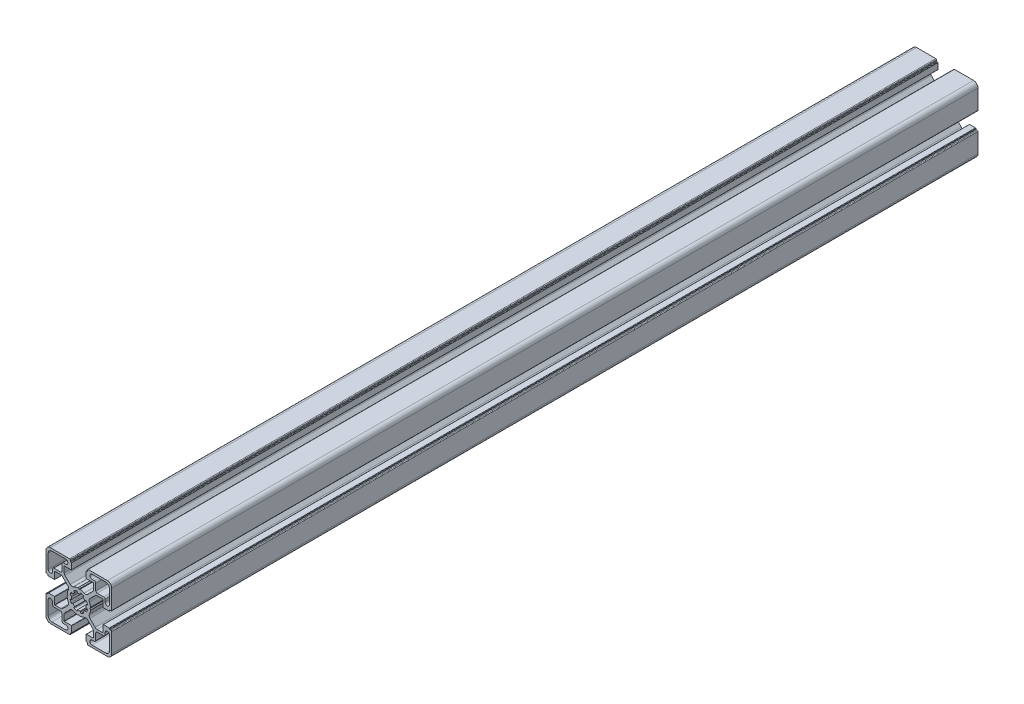
from build123d import *

# Parameters (mm, degrees)
BASE_EXTRUDE_DEPTH = 593


with BuildPart() as part:
    # Sketch1 → Base-Extrude (new body)
    with BuildSketch(Plane.XY):
        with BuildLine():
            Line((7.973976585, 0.792591518), (7.540060475, 0.046829556))
            ThreePointArc((7.540060475, 0.046829556), (7.534295984, 0.023675638), (7.531329941, 0))
            ThreePointArc((7.531329941, 0), (7.534295984, -0.023675638), (7.540060475, -0.046829556))
            Line((7.540060475, -0.046829556), (7.973976585, -0.792591518))
            ThreePointArc((7.973976585, -0.792591518), (7.996666421, -0.851255641), (8.000014047, -0.914065683))
            ThreePointArc((8.000014047, -0.914065683), (7.719730741, -2.298395946), (7.20036345, -3.611859543))
            ThreePointArc((7.20036345, -3.611859543), (7.018857217, -4.793954471), (7.563483933, -5.85869607))
            Line((7.563483933, -5.85869607), (11.129779889, -9.424988026))
            ThreePointArc((11.129779889, -9.424988026), (11.760624613, -9.84650461), (12.504756513, -9.99452154))
            Line((12.504756513, -9.99452154), (16.316902451, -9.99452154))
            ThreePointArc((16.316902451, -9.99452154), (16.458324055, -9.935942793), (16.516902802, -9.794521189))
            Line((16.516902802, -9.794521189), (16.516902802, -5.200014226))
            ThreePointArc((16.516902802, -5.200014226), (16.575481548, -5.058592621), (16.716903152, -5.000013875))
            Line((16.716903152, -5.000013875), (20.719599904, -5.000013875))
            ThreePointArc((20.719599904, -5.000013875), (20.931731427, -5.087881629), (21.01959918, -5.300013151))
            Line((21.01959918, -5.300013151), (21.01959918, -5.500004099))
            ThreePointArc((21.01959918, -5.500004099), (21.10746708, -5.712135974), (21.319598956, -5.800003874))
            Line((21.319598956, -5.800003874), (21.999979514, -5.800003874))
            ThreePointArc((21.999979514, -5.800003874), (22.35353264, -5.946450374), (22.49997914, -6.300003501))
            Line((22.49997914, -6.300003501), (22.49997914, -19.500016116))
            ThreePointArc((22.49997914, -19.500016116), (21.62130014, -21.621334875), (19.499981381, -22.500013875))
            Line((19.499981381, -22.500013875), (6.375709012, -22.500013875))
            ThreePointArc((6.375709012, -22.500013875), (6.022155886, -22.353567375), (5.875709386, -22.000014249))
            Line((5.875709386, -22.000014249), (5.875709386, -21.30001315))
            ThreePointArc((5.875709386, -21.30001315), (5.787841632, -21.087881628), (5.57571011, -21.000013874))
            Line((5.57571011, -21.000013874), (5.299998776, -21.000013874))
            ThreePointArc((5.299998776, -21.000013874), (5.087867607, -20.912146267), (5, -20.700015099))
            Line((5, -20.700015099), (5, -16.666812433))
            ThreePointArc((5, -16.666812433), (5.058578893, -16.525390475), (5.200000851, -16.466811582))
            Line((5.200000851, -16.466811582), (9.905385218, -16.466811582))
            ThreePointArc((9.905385218, -16.466811582), (10.046806822, -16.408232835), (10.105385569, -16.266811231))
            Line((10.105385569, -16.266811231), (10.105385569, -12.471582956))
            ThreePointArc((10.105385569, -12.471582956), (9.953144588, -11.706215861), (9.519598955, -11.057368968))
            Line((9.519598955, -11.057368968), (5.944897989, -7.482668002))
            ThreePointArc((5.944897989, -7.482668002), (4.854601835, -6.967833724), (3.666499237, -7.173289937))
            ThreePointArc((3.666499237, -7.173289937), (2.309136684, -7.713848333), (0.876396038, -8.000013875))
            ThreePointArc((0.876396038, -8.000013875), (0.81356491, -7.997088573), (0.754749577, -7.974793627))
            Line((0.754749577, -7.974793627), (0.11262846, -7.606936933))
            ThreePointArc((0.11262846, -7.606936933), (0.062963903, -7.559088739), (0, -7.530953975))
            ThreePointArc((0, -7.530953975), (-0.062963903, -7.559088739), (-0.11262846, -7.606936933))
            Line((-0.11262846, -7.606936933), (-0.754749577, -7.974793627))
            ThreePointArc((-0.754749577, -7.974793627), (-0.81356491, -7.997088573), (-0.876396038, -8.000013875))
            ThreePointArc((-0.876396038, -8.000013875), (-2.309136684, -7.713848333), (-3.666499237, -7.173289937))
            ThreePointArc((-3.666499237, -7.173289937), (-4.854601835, -6.967833724), (-5.944897989, -7.482668002))
            Line((-5.944897989, -7.482668002), (-9.519598955, -11.057368968))
            ThreePointArc((-9.519598955, -11.057368968), (-9.953144588, -11.706215861), (-10.105385569, -12.471582956))
            Line((-10.105385569, -12.471582956), (-10.105385569, -16.266811231))
            ThreePointArc((-10.105385569, -16.266811231), (-10.046806822, -16.408232835), (-9.905385218, -16.466811582))
            Line((-9.905385218, -16.466811582), (-5.200000851, -16.466811582))
            ThreePointArc((-5.200000851, -16.466811582), (-5.058578893, -16.525390475), (-5, -16.666812433))
            Line((-5, -16.666812433), (-5, -20.700015099))
            ThreePointArc((-5, -20.700015099), (-5.087867607, -20.912146267), (-5.299998776, -21.000013874))
            Line((-5.299998776, -21.000013874), (-5.57571011, -21.000013874))
            ThreePointArc((-5.57571011, -21.000013874), (-5.787841632, -21.087881628), (-5.875709386, -21.30001315))
            Line((-5.875709386, -21.30001315), (-5.875709386, -22.000014249))
            ThreePointArc((-5.875709386, -22.000014249), (-6.022155886, -22.353567375), (-6.375709012, -22.500013875))
            Line((-6.375709012, -22.500013875), (-19.499981381, -22.500013875))
            ThreePointArc((-19.499981381, -22.500013875), (-21.62130014, -21.621334875), (-22.49997914, -19.500016116))
            Line((-22.49997914, -19.500016116), (-22.49997914, -6.300003501))
            ThreePointArc((-22.49997914, -6.300003501), (-22.35353264, -5.946450374), (-21.999979514, -5.800003874))
            Line((-21.999979514, -5.800003874), (-21.319598956, -5.800003874))
            ThreePointArc((-21.319598956, -5.800003874), (-21.10746708, -5.712135974), (-21.01959918, -5.500004099))
            Line((-21.01959918, -5.500004099), (-21.01959918, -5.300013151))
            ThreePointArc((-21.01959918, -5.300013151), (-20.931731427, -5.087881629), (-20.719599904, -5.000013875))
            Line((-20.719599904, -5.000013875), (-16.716903152, -5.000013875))
            ThreePointArc((-16.716903152, -5.000013875), (-16.575481548, -5.058592621), (-16.516902802, -5.200014226))
            Line((-16.516902802, -5.200014226), (-16.516902802, -9.794521189))
            ThreePointArc((-16.516902802, -9.794521189), (-16.458324055, -9.935942793), (-16.316902451, -9.99452154))
            Line((-16.316902451, -9.99452154), (-12.504756513, -9.99452154))
            ThreePointArc((-12.504756513, -9.99452154), (-11.760624613, -9.84650461), (-11.129779889, -9.424988026))
            Line((-11.129779889, -9.424988026), (-7.563483933, -5.85869607))
            ThreePointArc((-7.563483933, -5.85869607), (-7.018857217, -4.793954471), (-7.20036345, -3.611859543))
            ThreePointArc((-7.20036345, -3.611859543), (-7.719730741, -2.298395946), (-8.000014047, -0.914065683))
            ThreePointArc((-8.000014047, -0.914065683), (-7.996666421, -0.851255641), (-7.973976585, -0.792591518))
            Line((-7.973976585, -0.792591518), (-7.540060475, -0.046829556))
            ThreePointArc((-7.540060475, -0.046829556), (-7.534295984, -0.023675638), (-7.531329941, 0))
            ThreePointArc((-7.531329941, 0), (-7.534295984, 0.023675638), (-7.540060475, 0.046829556))
            Line((-7.540060475, 0.046829556), (-7.973976585, 0.792591518))
            ThreePointArc((-7.973976585, 0.792591518), (-7.996666421, 0.851255641), (-8.000014047, 0.914065683))
            ThreePointArc((-8.000014047, 0.914065683), (-7.719730741, 2.298395946), (-7.20036345, 3.611859543))
            ThreePointArc((-7.20036345, 3.611859543), (-7.018857217, 4.793954471), (-7.563483933, 5.85869607))
            Line((-7.563483933, 5.85869607), (-11.129779889, 9.424988026))
            ThreePointArc((-11.129779889, 9.424988026), (-11.760624613, 9.84650461), (-12.504756513, 9.99452154))
            Line((-12.504756513, 9.99452154), (-16.316902451, 9.99452154))
            ThreePointArc((-16.316902451, 9.99452154), (-16.458324055, 9.935942793), (-16.516902802, 9.794521189))
            Line((-16.516902802, 9.794521189), (-16.516902802, 5.200014226))
            ThreePointArc((-16.516902802, 5.200014226), (-16.575481548, 5.058592621), (-16.716903152, 5.000013875))
            Line((-16.716903152, 5.000013875), (-20.719599904, 5.000013875))
            ThreePointArc((-20.719599904, 5.000013875), (-20.931731427, 5.087881629), (-21.01959918, 5.300013151))
            Line((-21.01959918, 5.300013151), (-21.01959918, 5.500004099))
            ThreePointArc((-21.01959918, 5.500004099), (-21.10746708, 5.712135974), (-21.319598956, 5.800003874))
            Line((-21.319598956, 5.800003874), (-21.999979514, 5.800003874))
            ThreePointArc((-21.999979514, 5.800003874), (-22.35353264, 5.946450374), (-22.49997914, 6.300003501))
            Line((-22.49997914, 6.300003501), (-22.49997914, 19.500016116))
            ThreePointArc((-22.49997914, 19.500016116), (-21.62130014, 21.621334875), (-19.499981381, 22.500013875))
            Line((-19.499981381, 22.500013875), (-6.375709012, 22.500013875))
            ThreePointArc((-6.375709012, 22.500013875), (-6.022155886, 22.353567375), (-5.875709386, 22.000014249))
            Line((-5.875709386, 22.000014249), (-5.875709386, 21.30001315))
            ThreePointArc((-5.875709386, 21.30001315), (-5.787841632, 21.087881628), (-5.57571011, 21.000013874))
            Line((-5.57571011, 21.000013874), (-5.299998776, 21.000013874))
            ThreePointArc((-5.299998776, 21.000013874), (-5.087867607, 20.912146267), (-5, 20.700015099))
            Line((-5, 20.700015099), (-5, 16.666812433))
            ThreePointArc((-5, 16.666812433), (-5.058578893, 16.525390475), (-5.200000851, 16.466811582))
            Line((-5.200000851, 16.466811582), (-9.905385218, 16.466811582))
            ThreePointArc((-9.905385218, 16.466811582), (-10.046806822, 16.408232835), (-10.105385569, 16.266811231))
            Line((-10.105385569, 16.266811231), (-10.105385569, 12.471582956))
            ThreePointArc((-10.105385569, 12.471582956), (-9.953144588, 11.706215861), (-9.519598955, 11.057368968))
            Line((-9.519598955, 11.057368968), (-5.944897989, 7.482668002))
            ThreePointArc((-5.944897989, 7.482668002), (-4.854601835, 6.967833724), (-3.666499237, 7.173289937))
            ThreePointArc((-3.666499237, 7.173289937), (-2.309136684, 7.713848333), (-0.876396038, 8.000013875))
            ThreePointArc((-0.876396038, 8.000013875), (-0.81356491, 7.997088573), (-0.754749577, 7.974793627))
            Line((-0.754749577, 7.974793627), (-0.11262846, 7.606936933))
            ThreePointArc((-0.11262846, 7.606936933), (-0.062963903, 7.559088739), (0, 7.530953975))
            ThreePointArc((0, 7.530953975), (0.062963903, 7.559088739), (0.11262846, 7.606936933))
            Line((0.11262846, 7.606936933), (0.754749577, 7.974793627))
            ThreePointArc((0.754749577, 7.974793627), (0.81356491, 7.997088573), (0.876396038, 8.000013875))
            ThreePointArc((0.876396038, 8.000013875), (2.309136684, 7.713848333), (3.666499237, 7.173289937))
            ThreePointArc((3.666499237, 7.173289937), (4.854601835, 6.967833724), (5.944897989, 7.482668002))
            Line((5.944897989, 7.482668002), (9.519598955, 11.057368968))
            ThreePointArc((9.519598955, 11.057368968), (9.953144588, 11.706215861), (10.105385569, 12.471582956))
            Line((10.105385569, 12.471582956), (10.105385569, 16.266811231))
            ThreePointArc((10.105385569, 16.266811231), (10.046806822, 16.408232835), (9.905385218, 16.466811582))
            Line((9.905385218, 16.466811582), (5.200000851, 16.466811582))
            ThreePointArc((5.200000851, 16.466811582), (5.058578893, 16.525390475), (5, 16.666812433))
            Line((5, 16.666812433), (5, 20.700015099))
            ThreePointArc((5, 20.700015099), (5.087867607, 20.912146267), (5.299998776, 21.000013874))
            Line((5.299998776, 21.000013874), (5.57571011, 21.000013874))
            ThreePointArc((5.57571011, 21.000013874), (5.787841632, 21.087881628), (5.875709386, 21.30001315))
            Line((5.875709386, 21.30001315), (5.875709386, 22.000014249))
            ThreePointArc((5.875709386, 22.000014249), (6.022155886, 22.353567375), (6.375709012, 22.500013875))
            Line((6.375709012, 22.500013875), (19.499981381, 22.500013875))
            ThreePointArc((19.499981381, 22.500013875), (21.62130014, 21.621334875), (22.49997914, 19.500016116))
            Line((22.49997914, 19.500016116), (22.49997914, 6.300003501))
            ThreePointArc((22.49997914, 6.300003501), (22.35353264, 5.946450374), (21.999979514, 5.800003874))
            Line((21.999979514, 5.800003874), (21.319598956, 5.800003874))
            ThreePointArc((21.319598956, 5.800003874), (21.10746708, 5.712135974), (21.01959918, 5.500004099))
            Line((21.01959918, 5.500004099), (21.01959918, 5.300013151))
            ThreePointArc((21.01959918, 5.300013151), (20.931731427, 5.087881629), (20.719599904, 5.000013875))
            Line((20.719599904, 5.000013875), (16.716903152, 5.000013875))
            ThreePointArc((16.716903152, 5.000013875), (16.575481548, 5.058592621), (16.516902802, 5.200014226))
            Line((16.516902802, 5.200014226), (16.516902802, 9.794521189))
            ThreePointArc((16.516902802, 9.794521189), (16.458324055, 9.935942793), (16.316902451, 9.99452154))
            Line((16.316902451, 9.99452154), (12.504756513, 9.99452154))
            ThreePointArc((12.504756513, 9.99452154), (11.760624613, 9.84650461), (11.129779889, 9.424988026))
            Line((11.129779889, 9.424988026), (7.563483933, 5.85869607))
            ThreePointArc((7.563483933, 5.85869607), (7.018857217, 4.793954471), (7.20036345, 3.611859543))
            ThreePointArc((7.20036345, 3.611859543), (7.719730741, 2.298395946), (8.000014047, 0.914065683))
            ThreePointArc((8.000014047, 0.914065683), (7.996666421, 0.851255641), (7.973976585, 0.792591518))
        make_face()
        with BuildLine():
            Line((10.549978885, 18.000013874), (8.999979138, 18.000013874))
            ThreePointArc((8.999979138, 18.000013874), (7.499979138, 19.500013874), (8.999979138, 21.000013874))
            Line((8.999979138, 21.000013874), (18.499981006, 21.000013874))
            ThreePointArc((18.499981006, 21.000013874), (20.267746638, 20.267781374), (20.999979138, 18.500015742))
            Line((20.999979138, 18.500015742), (20.999979138, 9.000204874))
            ThreePointArc((20.999979138, 9.000204874), (19.499979138, 7.500204874), (17.999979138, 9.000204874))
            Line((17.999979138, 9.000204874), (17.999979138, 10.550013621))
            ThreePointArc((17.999979138, 10.550013621), (17.707086138, 11.257119874), (16.999979885, 11.550012874))
            Line((16.999979885, 11.550012874), (12.549977391, 11.550012874))
            ThreePointArc((12.549977391, 11.550012874), (11.842871138, 11.842905874), (11.549978138, 12.550012127))
            Line((11.549978138, 12.550012127), (11.549978138, 17.000014621))
            ThreePointArc((11.549978138, 17.000014621), (11.257085138, 17.707120874), (10.549978885, 18.000013874))
        make_face(mode=Mode.SUBTRACT)
        with BuildLine():
            Line((-0.867388737, 4.924188946), (-0.96752168, 5.481112935))
            ThreePointArc((-0.96752168, 5.481112935), (-1.187855719, 5.829589164), (-1.595071417, 5.894072848))
            ThreePointArc((-1.595071417, 5.894072848), (-2.338895973, 5.643477696), (-3.04438497, 5.299445466))
            ThreePointArc((-3.04438497, 5.299445466), (-3.284615367, 4.964275075), (-3.191311906, 4.562598216))
            Line((-3.191311906, 4.562598216), (-2.864000421, 4.09847552))
            ThreePointArc((-2.864000421, 4.09847552), (-3.53013295, 3.540926624), (-4.08971289, 2.876499344))
            Line((-4.08971289, 2.876499344), (-4.566777651, 3.208162503))
            ThreePointArc((-4.566777651, 3.208162503), (-4.968960845, 3.298770682), (-5.302497889, 3.056460542))
            ThreePointArc((-5.302497889, 3.056460542), (-5.651259984, 2.353310881), (-5.906847665, 1.611199444))
            ThreePointArc((-5.906847665, 1.611199444), (-5.839752063, 1.204293023), (-5.489730697, 0.98621116))
            Line((-5.489730697, 0.98621116), (-4.920545766, 0.887822825))
            ThreePointArc((-4.920545766, 0.887822825), (-4.980096828, 0.445685524), (-5, 0))
            ThreePointArc((-5, 0), (-4.980096828, -0.445685524), (-4.920545766, -0.887822825))
            Line((-4.920545766, -0.887822825), (-5.489730697, -0.98621116))
            ThreePointArc((-5.489730697, -0.98621116), (-5.839752063, -1.204293023), (-5.906847665, -1.611199444))
            ThreePointArc((-5.906847665, -1.611199444), (-5.651259984, -2.353310881), (-5.302497889, -3.056460542))
            ThreePointArc((-5.302497889, -3.056460542), (-4.968960845, -3.298770682), (-4.566777651, -3.208162503))
            Line((-4.566777651, -3.208162503), (-4.08971289, -2.876499344))
            ThreePointArc((-4.08971289, -2.876499344), (-3.53013295, -3.540926624), (-2.864000421, -4.09847552))
            Line((-2.864000421, -4.09847552), (-3.191311906, -4.562598216))
            ThreePointArc((-3.191311906, -4.562598216), (-3.284615367, -4.964275075), (-3.04438497, -5.299445466))
            ThreePointArc((-3.04438497, -5.299445466), (-2.338895973, -5.643477696), (-1.595071417, -5.894072848))
            ThreePointArc((-1.595071417, -5.894072848), (-1.187855719, -5.829589164), (-0.96752168, -5.481112935))
            Line((-0.96752168, -5.481112935), (-0.867388737, -4.924188946))
            ThreePointArc((-0.867388737, -4.924188946), (0, -5), (0.867388737, -4.924188946))
            Line((0.867388737, -4.924188946), (0.96752168, -5.481112935))
            ThreePointArc((0.96752168, -5.481112935), (1.187855719, -5.829589164), (1.595071417, -5.894072848))
            ThreePointArc((1.595071417, -5.894072848), (2.338895973, -5.643477696), (3.04438497, -5.299445466))
            ThreePointArc((3.04438497, -5.299445466), (3.284615367, -4.964275075), (3.191311906, -4.562598216))
            Line((3.191311906, -4.562598216), (2.864000421, -4.09847552))
            ThreePointArc((2.864000421, -4.09847552), (3.53013295, -3.540926624), (4.08971289, -2.876499344))
            Line((4.08971289, -2.876499344), (4.566777651, -3.208162503))
            ThreePointArc((4.566777651, -3.208162503), (4.968960845, -3.298770682), (5.302497889, -3.056460542))
            ThreePointArc((5.302497889, -3.056460542), (5.651259984, -2.353310881), (5.906847665, -1.611199444))
            ThreePointArc((5.906847665, -1.611199444), (5.839752063, -1.204293023), (5.489730697, -0.98621116))
            Line((5.489730697, -0.98621116), (4.920545766, -0.887822825))
            ThreePointArc((4.920545766, -0.887822825), (4.980096828, -0.445685524), (5, 0))
            ThreePointArc((5, 0), (4.980096828, 0.445685524), (4.920545766, 0.887822825))
            Line((4.920545766, 0.887822825), (5.489730697, 0.98621116))
            ThreePointArc((5.489730697, 0.98621116), (5.839752063, 1.204293023), (5.906847665, 1.611199444))
            ThreePointArc((5.906847665, 1.611199444), (5.651259984, 2.353310881), (5.302497889, 3.056460542))
            ThreePointArc((5.302497889, 3.056460542), (4.968960845, 3.298770682), (4.566777651, 3.208162503))
            Line((4.566777651, 3.208162503), (4.08971289, 2.876499344))
            ThreePointArc((4.08971289, 2.876499344), (3.53013295, 3.540926624), (2.864000421, 4.09847552))
            Line((2.864000421, 4.09847552), (3.191311906, 4.562598216))
            ThreePointArc((3.191311906, 4.562598216), (3.284615367, 4.964275075), (3.04438497, 5.299445466))
            ThreePointArc((3.04438497, 5.299445466), (2.338895973, 5.643477696), (1.595071417, 5.894072848))
            ThreePointArc((1.595071417, 5.894072848), (1.187855719, 5.829589164), (0.96752168, 5.481112935))
            Line((0.96752168, 5.481112935), (0.867388737, 4.924188946))
            ThreePointArc((0.867388737, 4.924188946), (0, 5), (-0.867388737, 4.924188946))
        make_face(mode=Mode.SUBTRACT)
        with BuildLine():
            Line((-10.549978885, -18.000013874), (-8.999979138, -18.000013874))
            ThreePointArc((-8.999979138, -18.000013874), (-7.499979138, -19.500013874), (-8.999979138, -21.000013874))
            Line((-8.999979138, -21.000013874), (-18.499981006, -21.000013874))
            ThreePointArc((-18.499981006, -21.000013874), (-20.267746638, -20.267781374), (-20.999979138, -18.500015742))
            Line((-20.999979138, -18.500015742), (-20.999979138, -9.000204874))
            ThreePointArc((-20.999979138, -9.000204874), (-19.499979138, -7.500204874), (-17.999979138, -9.000204874))
            Line((-17.999979138, -9.000204874), (-17.999979138, -10.550013621))
            ThreePointArc((-17.999979138, -10.550013621), (-17.707086138, -11.257119874), (-16.999979885, -11.550012874))
            Line((-16.999979885, -11.550012874), (-12.549977391, -11.550012874))
            ThreePointArc((-12.549977391, -11.550012874), (-11.842871138, -11.842905874), (-11.549978138, -12.550012127))
            Line((-11.549978138, -12.550012127), (-11.549978138, -17.000014621))
            ThreePointArc((-11.549978138, -17.000014621), (-11.257085138, -17.707120874), (-10.549978885, -18.000013874))
        make_face(mode=Mode.SUBTRACT)
        with BuildLine():
            Line((-11.549978138, 12.550012127), (-11.549978138, 17.000014621))
            ThreePointArc((-11.549978138, 17.000014621), (-11.257085138, 17.707120874), (-10.549978885, 18.000013874))
            Line((-10.549978885, 18.000013874), (-8.999979138, 18.000013874))
            ThreePointArc((-8.999979138, 18.000013874), (-7.499979138, 19.500013874), (-8.999979138, 21.000013874))
            Line((-8.999979138, 21.000013874), (-18.499981006, 21.000013874))
            ThreePointArc((-18.499981006, 21.000013874), (-20.267746638, 20.267781374), (-20.999979138, 18.500015742))
            Line((-20.999979138, 18.500015742), (-20.999979138, 9.000204874))
            ThreePointArc((-20.999979138, 9.000204874), (-19.499979138, 7.500204874), (-17.999979138, 9.000204874))
            Line((-17.999979138, 9.000204874), (-17.999979138, 10.550013621))
            ThreePointArc((-17.999979138, 10.550013621), (-17.707086138, 11.257119874), (-16.999979885, 11.550012874))
            Line((-16.999979885, 11.550012874), (-12.549977391, 11.550012874))
            ThreePointArc((-12.549977391, 11.550012874), (-11.842871138, 11.842905874), (-11.549978138, 12.550012127))
        make_face(mode=Mode.SUBTRACT)
        with BuildLine():
            Line((11.549978138, -12.550012127), (11.549978138, -17.000014621))
            ThreePointArc((11.549978138, -17.000014621), (11.257085138, -17.707120874), (10.549978885, -18.000013874))
            Line((10.549978885, -18.000013874), (8.999979138, -18.000013874))
            ThreePointArc((8.999979138, -18.000013874), (7.499979138, -19.500013874), (8.999979138, -21.000013874))
            Line((8.999979138, -21.000013874), (18.499981006, -21.000013874))
            ThreePointArc((18.499981006, -21.000013874), (20.267746638, -20.267781374), (20.999979138, -18.500015742))
            Line((20.999979138, -18.500015742), (20.999979138, -9.000204874))
            ThreePointArc((20.999979138, -9.000204874), (19.499979138, -7.500204874), (17.999979138, -9.000204874))
            Line((17.999979138, -9.000204874), (17.999979138, -10.550013621))
            ThreePointArc((17.999979138, -10.550013621), (17.707086138, -11.257119874), (16.999979885, -11.550012874))
            Line((16.999979885, -11.550012874), (12.549977391, -11.550012874))
            ThreePointArc((12.549977391, -11.550012874), (11.842871138, -11.842905874), (11.549978138, -12.550012127))
        make_face(mode=Mode.SUBTRACT)
    extrude(amount=-BASE_EXTRUDE_DEPTH)


solid = part.part
